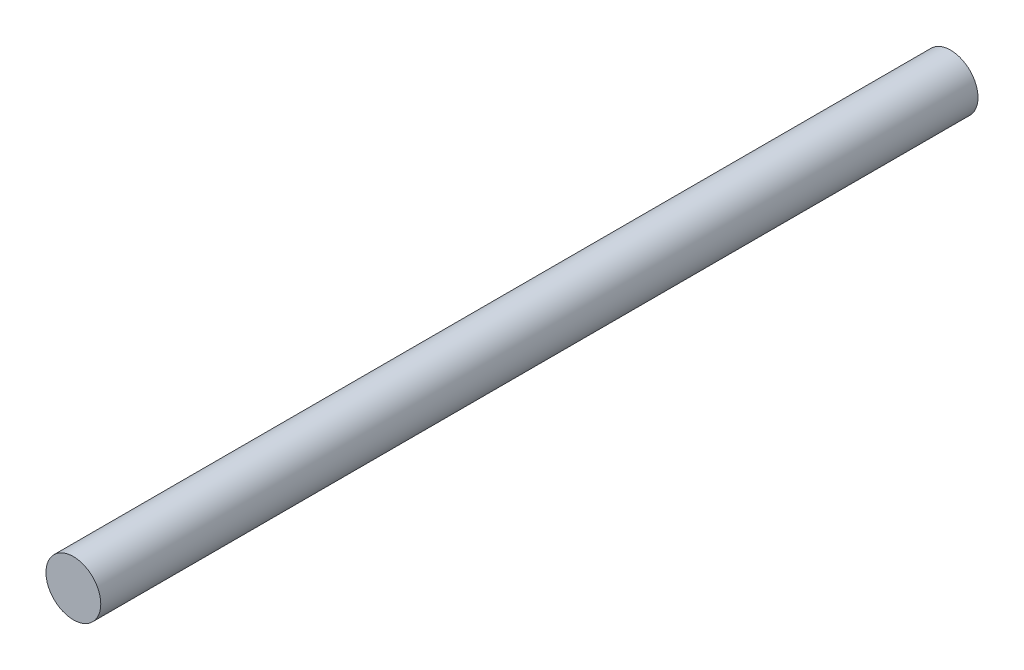
from build123d import *

# Parameters (mm, degrees)
SKETCH1_R           = 3.175
BOSS_EXTRUDE1_DEPTH = 101.6


with BuildPart() as part:
    # Sketch1 → Boss-Extrude1 (new body)
    with BuildSketch(Plane.XY):
        Circle(SKETCH1_R)
    extrude(amount=BOSS_EXTRUDE1_DEPTH)


solid = part.part
